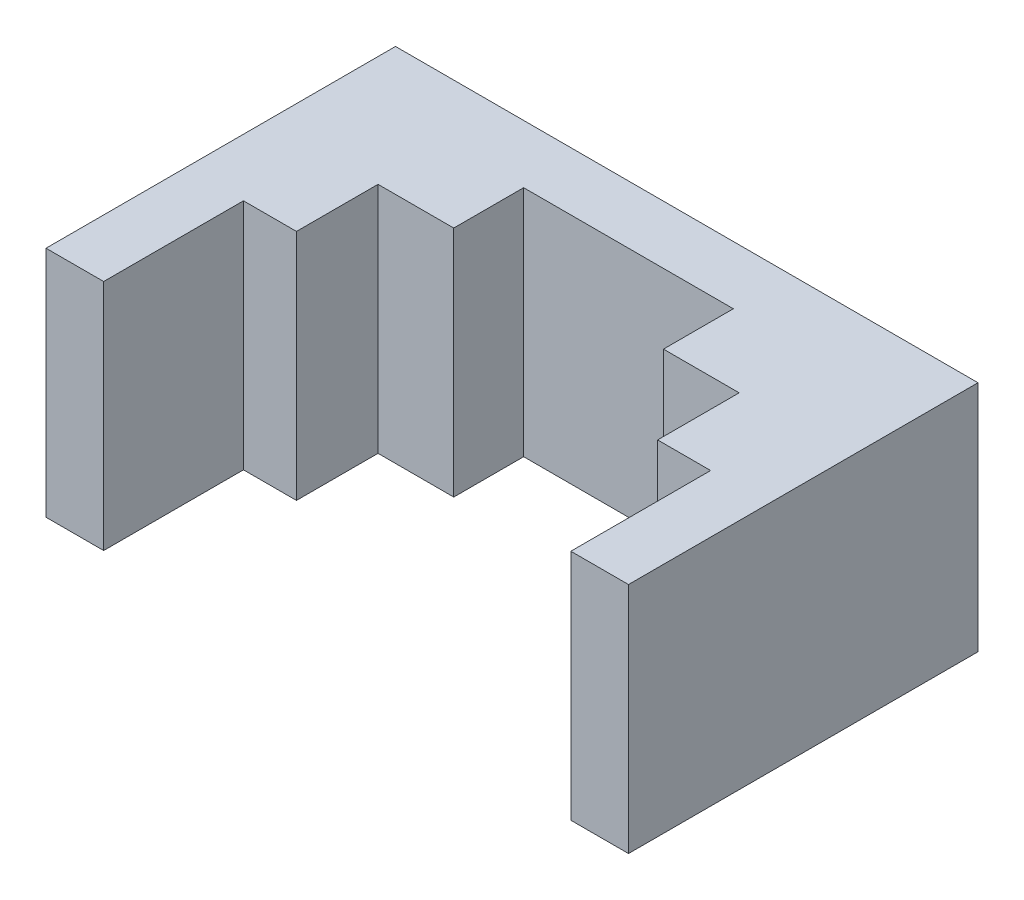
from build123d import *

# Parameters (mm, degrees)
SKETCH1_W           = 25
SKETCH1_H           = 10
BOSS_EXTRUDE1_DEPTH = 15
SKETCH2_W           = 20.05
SKETCH2_H           = 10
CUT_EXTRUDE1_DEPTH  = 6
SKETCH3_W           = 9
SKETCH3_H           = 10
CUT_EXTRUDE2_DEPTH  = 6.5
SKETCH4_W           = 15.5
SKETCH4_H           = 10
CUT_EXTRUDE3_DEPTH  = 3.5


with BuildPart() as part:
    # Sketch1 → Boss-Extrude1 (new body)
    with BuildSketch(Plane.XY):
        Rectangle(SKETCH1_W, SKETCH1_H)
    extrude(amount=BOSS_EXTRUDE1_DEPTH)

    # Sketch2 → Cut-Extrude1 (cut)
    with BuildSketch(Plane.XY.offset(15)):
        Rectangle(SKETCH2_W, SKETCH2_H)
    extrude(amount=-CUT_EXTRUDE1_DEPTH, mode=Mode.SUBTRACT)

    # Sketch3 → Cut-Extrude2 (cut)
    with BuildSketch(Plane.XY.offset(9)):
        Rectangle(SKETCH3_W, SKETCH3_H)
    extrude(amount=-CUT_EXTRUDE2_DEPTH, mode=Mode.SUBTRACT)

    # Sketch4 → Cut-Extrude3 (cut)
    with BuildSketch(Plane.XY.offset(9)):
        Rectangle(SKETCH4_W, SKETCH4_H)
    extrude(amount=-CUT_EXTRUDE3_DEPTH, mode=Mode.SUBTRACT)


solid = part.part
